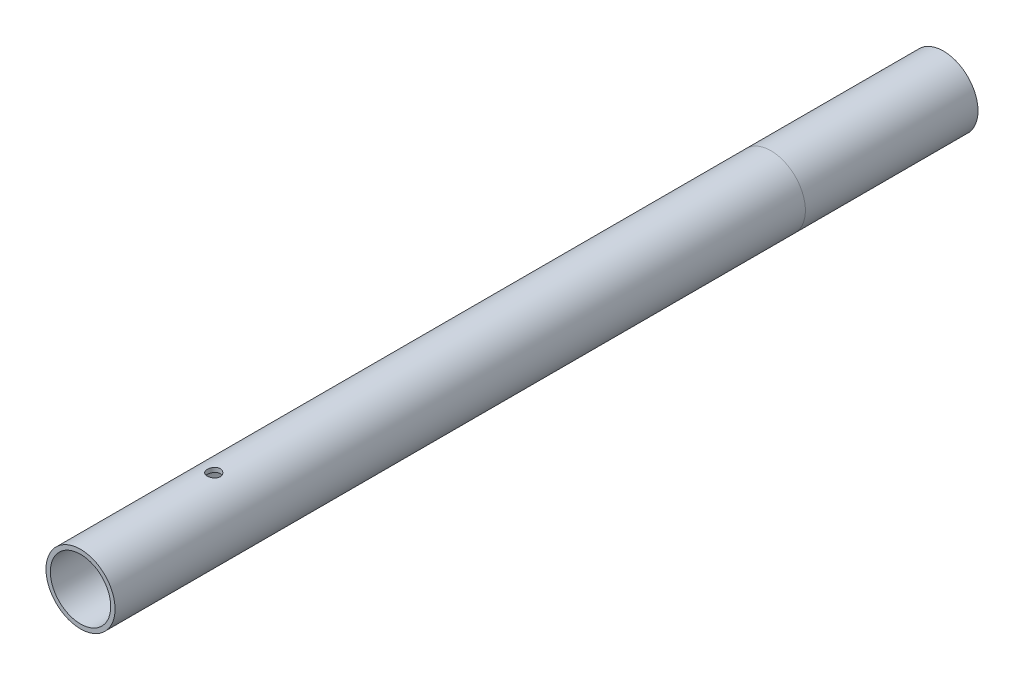
from build123d import *

# Parameters (mm, degrees)
SKETCH1_R               = 8
SKETCH1_R_2             = 7
BOSS_EXTRUDE1_DEPTH     = 200
SKETCH3_R               = 1.5
CUT_EXTRUDE1_DEPTH      = 9
CUT_EXTRUDE1_DEPTH_BACK = 9


with BuildPart() as part:
    # Sketch1 → Boss-Extrude1 (new body)
    with BuildSketch(Plane.XY):
        Circle(SKETCH1_R)
        Circle(SKETCH1_R_2, mode=Mode.SUBTRACT)
    extrude(amount=BOSS_EXTRUDE1_DEPTH)

    # Sketch3 → Cut-Extrude1 (cut, two sides)
    with BuildSketch(Plane(origin=(0, 0, 0), x_dir=(1, 0, 0), z_dir=(0, 1, 0))) as cut_extrude1_sk:
        with Locations((0, -169.13)):
            Circle(SKETCH3_R)
    extrude(amount=CUT_EXTRUDE1_DEPTH, mode=Mode.SUBTRACT)
    extrude(cut_extrude1_sk.sketch, amount=-CUT_EXTRUDE1_DEPTH_BACK, mode=Mode.SUBTRACT)


solid = part.part
